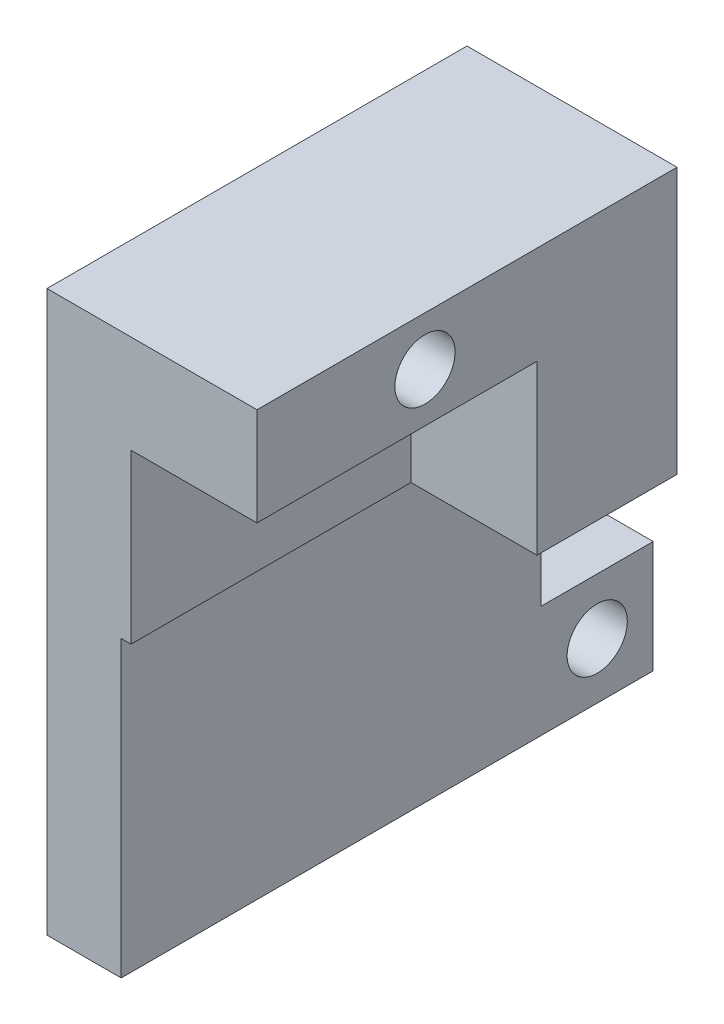
from build123d import *

# Parameters (mm, degrees)
SKETCH1_W           = 6
SKETCH1_H           = 35
BOSS_EXTRUDE1_DEPTH = 20
SKETCH2_W           = 35
SKETCH2_H           = 7
BOSS_EXTRUDE2_DEPTH = 9
SKETCH6_R           = 2.15
CUT_EXTRUDE1_DEPTH  = 16
SKETCH7_W           = 6
SKETCH7_H           = 8
BOSS_EXTRUDE3_DEPTH = 8
SKETCH8_R           = 2.15
CUT_EXTRUDE2_DEPTH  = 16
SKETCH9_W           = 9
SKETCH9_H           = 10
BOSS_EXTRUDE4_DEPTH = 12
CUT_EXTRUDE3_REACH  = 17
SKETCH10_W          = 5
SKETCH10_H          = 40
SKETCH11_W          = 30
SKETCH11_H          = 21
CUT_EXTRUDE4_DEPTH  = 0.7
SKETCH12_W          = 8
SKETCH12_H          = 8
CUT_EXTRUDE5_DEPTH  = 0.7


with BuildPart() as part:
    # Sketch1 → Boss-Extrude1 (new body, symmetric)
    with BuildSketch(Plane(origin=(0, 0, 0), x_dir=(1, 0, 0), z_dir=(0, 1, 0))):
        with Locations((-9.580645161, 13.951612903)):
            Rectangle(SKETCH1_W, SKETCH1_H)
    extrude(amount=BOSS_EXTRUDE1_DEPTH, both=True)

    # Sketch2 → Boss-Extrude2 (add)
    with BuildSketch(Plane(origin=(-6.580645161, 0, 0), x_dir=(0, 0, -1), z_dir=(1, 0, 0))):
        with Locations((13.951612903, 16.5)):
            Rectangle(SKETCH2_W, SKETCH2_H)
    extrude(amount=BOSS_EXTRUDE2_DEPTH)

    # Sketch6 → Cut-Extrude1 (cut, through all)
    with BuildSketch(Plane(origin=(2.419354839, 0, 0), x_dir=(0, 0, -1), z_dir=(1, 0, 0))):
        with Locations((13.451612903, 16.5)):
            Circle(SKETCH6_R)
    extrude(amount=-CUT_EXTRUDE1_DEPTH, mode=Mode.SUBTRACT)

    # Sketch7 → Boss-Extrude3 (add)
    with BuildSketch(Plane(origin=(0, 0, -31.451612903), x_dir=(-1, 0, 0), z_dir=(0, 0, -1))):
        with Locations((9.580645161, -16)):
            Rectangle(SKETCH7_W, SKETCH7_H)
    extrude(amount=BOSS_EXTRUDE3_DEPTH)

    # Sketch8 → Cut-Extrude2 (cut, through all)
    with BuildSketch(Plane.ZY.offset(12.580645161)):
        with Locations((-35.451612903, -16)):
            Circle(SKETCH8_R)
    extrude(amount=-CUT_EXTRUDE2_DEPTH, mode=Mode.SUBTRACT)

    # Sketch9 → Boss-Extrude4 (add)
    with BuildSketch(Plane.XZ.offset(-13)):
        with Locations((-2.080645161, -26.451612903)):
            Rectangle(SKETCH9_W, SKETCH9_H)
    extrude(amount=BOSS_EXTRUDE4_DEPTH)

    # Sketch10 → Cut-Extrude3 (cut, up to next)
    with BuildSketch(Plane.ZY.offset(12.580645161), mode=Mode.PRIVATE) as cut_extrude3_sk1:
        with Locations((1.048387097, 0)):
            Rectangle(SKETCH10_W, SKETCH10_H)
    cut_extrude3_tool1 = extrude(cut_extrude3_sk1.sketch, amount=-CUT_EXTRUDE3_REACH, mode=Mode.PRIVATE) & part.part
    add(cut_extrude3_tool1.solids().sort_by_distance((-12.580645, 0, 1.048387))[0], mode=Mode.SUBTRACT)

    # Sketch11 → Cut-Extrude4 (cut)
    with BuildSketch(Plane(origin=(-6.580645161, 0, 0), x_dir=(0, 0, -1), z_dir=(1, 0, 0))):
        with Locations((16.451612903, -9.5)):
            Rectangle(SKETCH11_W, SKETCH11_H)
    extrude(amount=-CUT_EXTRUDE4_DEPTH, mode=Mode.SUBTRACT)

    # Sketch12 → Cut-Extrude5 (cut)
    with BuildSketch(Plane(origin=(-6.580645161, 0, 0), x_dir=(0, 0, -1), z_dir=(1, 0, 0))):
        with Locations((35.451612903, -16)):
            Rectangle(SKETCH12_W, SKETCH12_H)
    extrude(amount=-CUT_EXTRUDE5_DEPTH, mode=Mode.SUBTRACT)


solid = part.part
